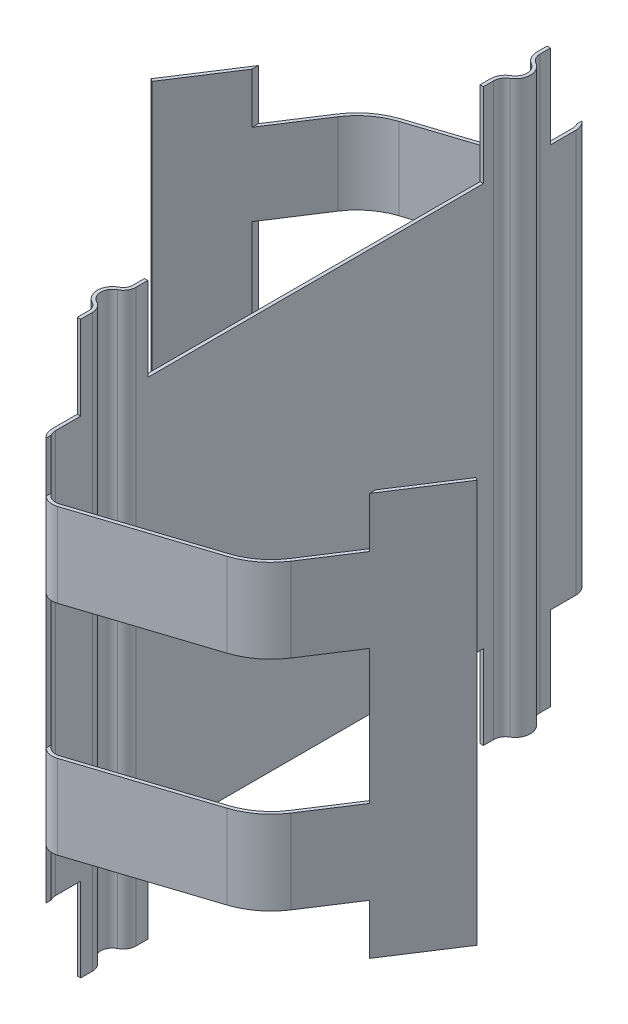
from build123d import *

# Parameters (mm, degrees)
EXTRUDE_THIN1_DEPTH      = 8.5
EXTRUDE_THIN1_DEPTH_BACK = 8.5
SKETCH2_W                = 10
SKETCH2_H                = 2.5
SKETCH2_W_2              = 2.5
EXTRUDE1_DEPTH           = 10
EXTRUDE1_DEPTH_BACK      = 10
SKETCH3_W                = 6.25
SKETCH3_H                = 4
EXTRUDE2_DEPTH           = 10
SKETCH4_W                = 6.25
SKETCH4_H                = 4
EXTRUDE3_DEPTH           = 10


with BuildPart() as part:
    # Sketch1 → Extrude-Thin1 (new body, two sides)
    with BuildSketch(Plane(origin=(0, 0, 0), x_dir=(1, 0, 0), z_dir=(0, 1, 0))) as extrude_thin1_sk:
        with BuildLine():
            Line((7.523762622, -2.697363846), (5.345206482, -6.052046118))
            ThreePointArc((5.345206482, -6.052046118), (4.896883661, -6.537039014), (4.312382013, -6.844560207))
            Line((4.312382013, -6.844560207), (0.508155948, -8.080628184))
            ThreePointArc((0.508155948, -8.080628184), (0.194275162, -8.030914352), (0.05, -7.747758404))
            Line((0.05, -7.747758404), (0.05, -6.652305648))
            ThreePointArc((0.05, -6.652305648), (-0.006212483, -6.453404557), (-0.158219178, -6.313349383))
            ThreePointArc((-0.158219178, -6.313349383), (-0.35, -6.001152824), (-0.158219178, -5.688956264))
            ThreePointArc((-0.158219178, -5.688956264), (-0.006212483, -5.548901091), (0.05, -5.35))
            Line((0.05, -5.35), (0.05, 5.307179677))
            ThreePointArc((0.05, 5.307179677), (0.096891109, 5.482179677), (0.225, 5.610288568))
            ThreePointArc((0.225, 5.610288568), (0.45, 6), (0.225, 6.389711432))
            ThreePointArc((0.225, 6.389711432), (0.096891109, 6.517820323), (0.05, 6.692820323))
            Line((0.05, 6.692820323), (0.05, 7.751254615))
            ThreePointArc((0.05, 7.751254615), (-0.135496636, 8.115312262), (-0.539057647, 8.179230047))
            Line((-0.539057647, 8.179230047), (-4.343283713, 6.943162069))
            ThreePointArc((-4.343283713, 6.943162069), (-4.957759804, 6.619870559), (-5.429073538, 6.110006233))
            Line((-5.429073538, 6.110006233), (-7.607629679, 2.755323961))
            Line((-7.607629679, 2.755323961), (-7.523762622, 2.700860058))
            Line((-7.523762622, 2.700860058), (-5.345206482, 6.055542329))
            ThreePointArc((-5.345206482, 6.055542329), (-4.896883661, 6.540535225), (-4.312382013, 6.848056418))
            Line((-4.312382013, 6.848056418), (-0.508155948, 8.084124395))
            ThreePointArc((-0.508155948, 8.084124395), (-0.194275162, 8.034410563), (-0.05, 7.751254615))
            Line((-0.05, 7.751254615), (-0.05, 6.692820323))
            ThreePointArc((-0.05, 6.692820323), (0.010288568, 6.467820323), (0.175, 6.303108891))
            ThreePointArc((0.175, 6.303108891), (0.35, 6), (0.175, 5.696891109))
            ThreePointArc((0.175, 5.696891109), (0.010288568, 5.532179677), (-0.05, 5.307179677))
            Line((-0.05, 5.307179677), (-0.05, -5.35))
            ThreePointArc((-0.05, -5.35), (-0.091419724, -5.496558698), (-0.203424658, -5.599757248))
            ThreePointArc((-0.203424658, -5.599757248), (-0.45, -6.001152824), (-0.203424658, -6.4025484))
            ThreePointArc((-0.203424658, -6.4025484), (-0.091419724, -6.505746949), (-0.05, -6.652305648))
            Line((-0.05, -6.652305648), (-0.05, -7.747758404))
            ThreePointArc((-0.05, -7.747758404), (0.135496636, -8.111816051), (0.539057647, -8.175733836))
            Line((0.539057647, -8.175733836), (4.343283713, -6.939665858))
            ThreePointArc((4.343283713, -6.939665858), (4.957759804, -6.616374348), (5.429073538, -6.106510022))
            Line((5.429073538, -6.106510022), (7.607629679, -2.75182775))
            Line((7.607629679, -2.75182775), (7.523762622, -2.697363846))
        make_face()
    extrude(amount=EXTRUDE_THIN1_DEPTH)
    extrude(extrude_thin1_sk.sketch, amount=-EXTRUDE_THIN1_DEPTH_BACK)

    # Sketch2 → Extrude1 (cut, two sides)
    with BuildSketch(Plane(origin=(0, 0, 0), x_dir=(0, 0, -1), z_dir=(1, 0, 0))) as extrude1_sk:
        with Locations((0, 7.25)):
            Rectangle(SKETCH2_W, SKETCH2_H)
        with Locations((0, -7.25)):
            Rectangle(SKETCH2_W, SKETCH2_H)
        with Locations((8.25, 7.25)):
            Rectangle(SKETCH2_W_2, SKETCH2_H)
        with Locations((-8.25, 7.25)):
            Rectangle(SKETCH2_W_2, SKETCH2_H)
        with Locations((8.25, -7.25)):
            Rectangle(SKETCH2_W_2, SKETCH2_H)
        with Locations((-8.25, -7.25)):
            Rectangle(SKETCH2_W_2, SKETCH2_H)
    extrude(amount=EXTRUDE1_DEPTH, mode=Mode.SUBTRACT)
    extrude(extrude1_sk.sketch, amount=-EXTRUDE1_DEPTH_BACK, mode=Mode.SUBTRACT)

    # Sketch3 → Extrude2 (cut)
    with BuildSketch(Plane(origin=(0, 0, 0), x_dir=(-1, 0, 0), z_dir=(0, 0, 1))):
        with Locations((-3.225, -6.5)):
            Rectangle(SKETCH3_W, SKETCH3_H)
        with Locations((-3.225, 0)):
            Rectangle(SKETCH3_W, SKETCH3_H)
        with Locations((-3.225, 6.5)):
            Rectangle(SKETCH3_W, SKETCH3_H)
    extrude(amount=EXTRUDE2_DEPTH, mode=Mode.SUBTRACT)

    # Sketch4 → Extrude3 (cut)
    with BuildSketch(Plane(origin=(0, 0, 0), x_dir=(-1, 0, 0), z_dir=(0, 0, 1))):
        with Locations((3.225, 6.5)):
            Rectangle(SKETCH4_W, SKETCH4_H)
        with Locations((3.225, -0.062819576)):
            Rectangle(SKETCH4_W, SKETCH4_H)
        with Locations((3.225, -6.5)):
            Rectangle(SKETCH4_W, SKETCH4_H)
    extrude(amount=-EXTRUDE3_DEPTH, mode=Mode.SUBTRACT)


solid = part.part
